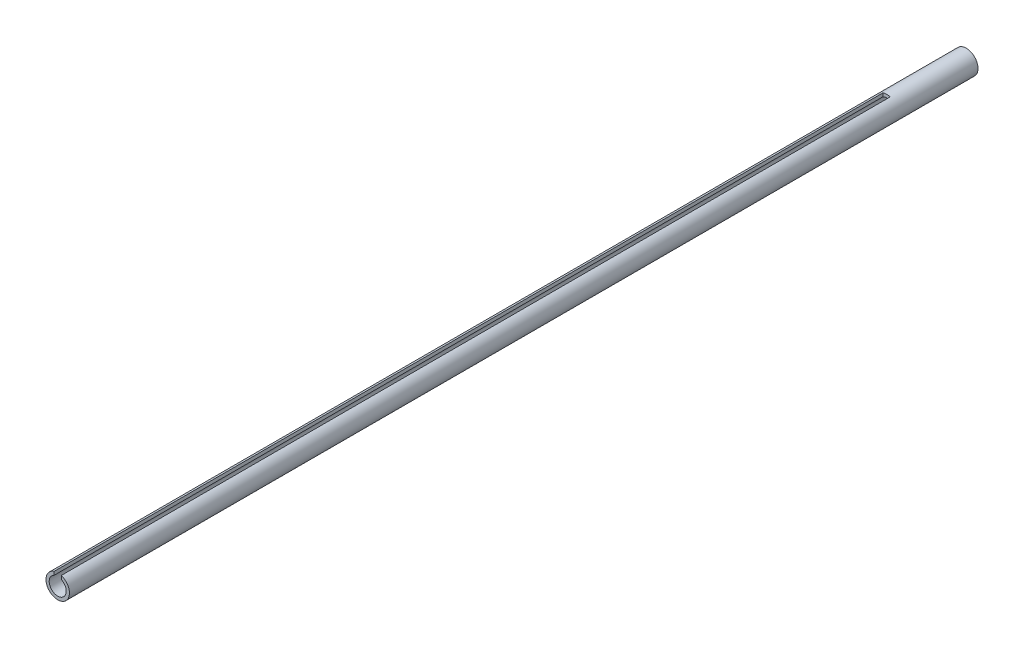
from build123d import *

# Parameters (mm, degrees)
SKETCH1_R           = 0.735
SKETCH1_R_2         = 0.535
BOSS_EXTRUDE1_DEPTH = 57
SKETCH2_W           = 0.45
SKETCH2_H           = 53
CUT_EXTRUDE1_DEPTH  = 58.009476844
SKETCH3_W           = 1
SKETCH3_H           = 2
CUT_EXTRUDE2_DEPTH  = 58.009476844


with BuildPart() as part:
    # Sketch1 → Boss-Extrude1 (new body)
    with BuildSketch(Plane.XY):
        Circle(SKETCH1_R)
        Circle(SKETCH1_R_2, mode=Mode.SUBTRACT)
    extrude(amount=BOSS_EXTRUDE1_DEPTH)

    # Sketch2 → Cut-Extrude1 (cut, through all)
    with BuildSketch(Plane(origin=(0, 0, 0), x_dir=(1, 0, 0), z_dir=(0, 1, 0))):
        with Locations((0, -31.5)):
            Rectangle(SKETCH2_W, SKETCH2_H)
    extrude(amount=CUT_EXTRUDE1_DEPTH, mode=Mode.SUBTRACT)

    # Sketch3 → Cut-Extrude2 (cut, through all)
    with BuildSketch(Plane(origin=(0, 0, 0), x_dir=(1, 0, 0), z_dir=(0, 1, 0))):
        with Locations((0, -22)):
            Rectangle(SKETCH3_W, SKETCH3_H)
    extrude(amount=-CUT_EXTRUDE2_DEPTH, mode=Mode.SUBTRACT)


solid = part.part
